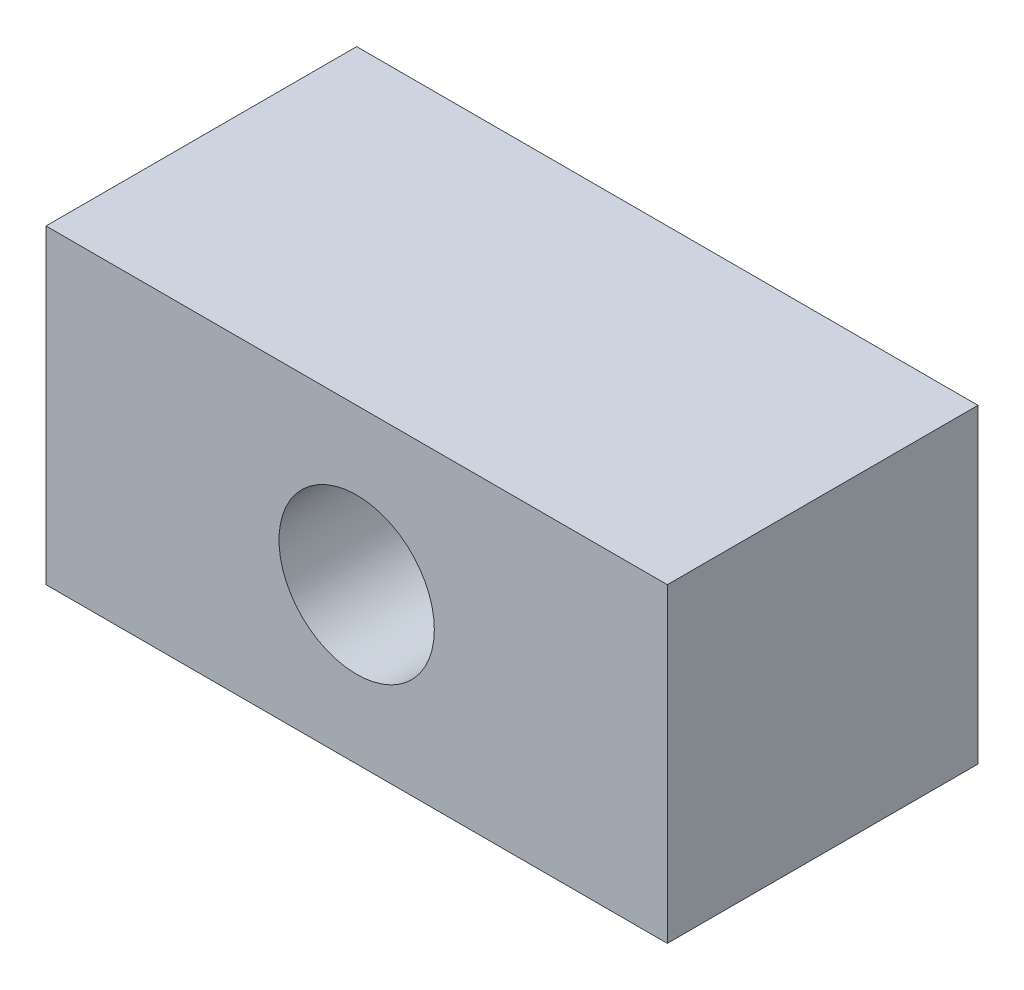
from build123d import *

# Parameters (mm, degrees)
SKETCH1_W           = 60
SKETCH1_H           = 30
SKETCH1_R           = 7.5
BOSS_EXTRUDE1_DEPTH = 30


with BuildPart() as part:
    # Sketch1 → Boss-Extrude1 (new body)
    with BuildSketch(Plane.XY):
        Rectangle(SKETCH1_W, SKETCH1_H)
        Circle(SKETCH1_R, mode=Mode.SUBTRACT)
    extrude(amount=BOSS_EXTRUDE1_DEPTH)


solid = part.part
